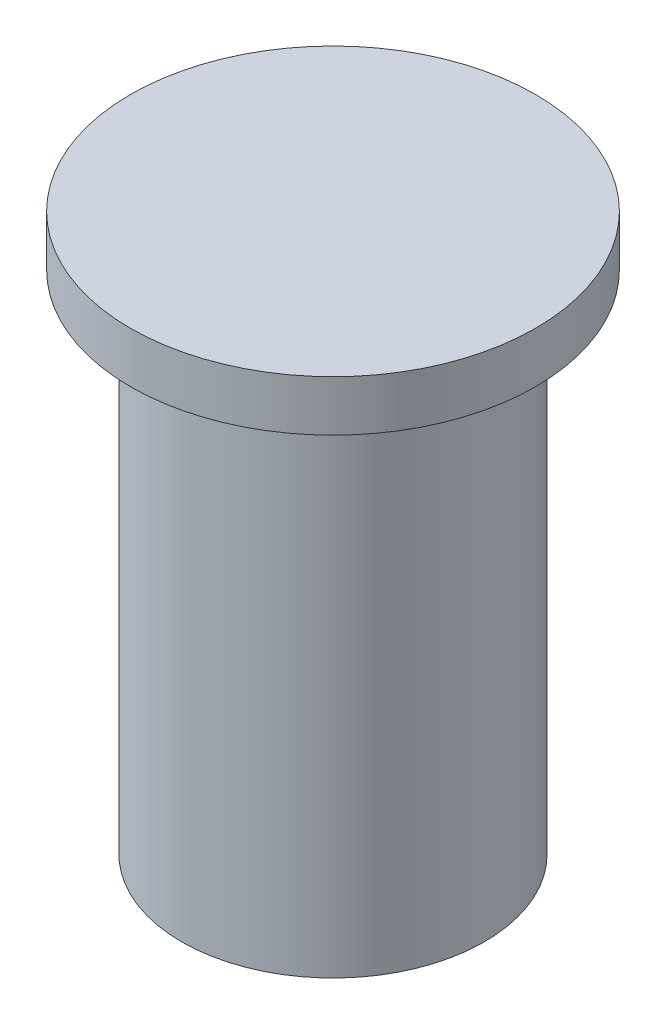
from build123d import *

# Parameters (mm, degrees)
SKETCH1_R           = 44.85
BOSS_EXTRUDE1_DEPTH = 150
SKETCH4_R           = 60
BOSS_EXTRUDE3_DEPTH = 15


with BuildPart() as part:
    # Sketch1 → Boss-Extrude1 (new body)
    with BuildSketch(Plane(origin=(0, 0, 0), x_dir=(1, 0, 0), z_dir=(0, 1, 0))):
        Circle(SKETCH1_R)
    extrude(amount=BOSS_EXTRUDE1_DEPTH)

    # Sketch4 → Boss-Extrude3 (add)
    with BuildSketch(Plane(origin=(0, 150, 0), x_dir=(1, 0, 0), z_dir=(0, 1, 0))):
        Circle(SKETCH4_R)
    extrude(amount=BOSS_EXTRUDE3_DEPTH)


solid = part.part
